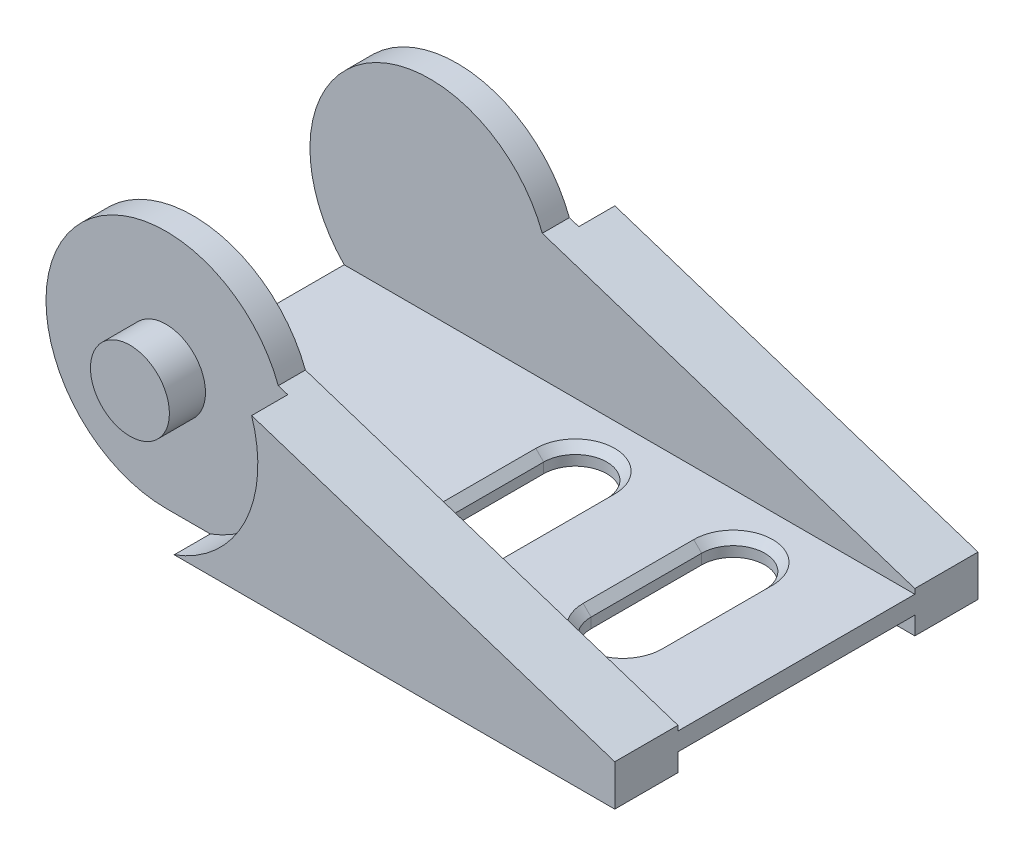
from build123d import *

# Parameters (mm, degrees)
BOSS_EXTRUDE1_DEPTH = 23
CUT_EXTRUDE1_DEPTH  = 24
SKETCH3_W           = 15
SKETCH3_H           = 12.914285714
CUT_EXTRUDE2_DEPTH  = 39.3
CUT_EXTRUDE4_DEPTH  = 3.285714286
SKETCH4_W           = 15
SKETCH4_H           = 1.142857143
CUT_EXTRUDE3_DEPTH  = 39.3
SKETCH_1_R          = 8.1
CUT_EXTRUDE_1_DEPTH = 2.285714
BOSS_EXTRUDE3_START = -2.285714
SKETCH7_R           = 2.5
BOSS_EXTRUDE3_DEPTH = 2.285714
EXTRUDE_START       = -20.714286
SKETCH7_2_R         = 2.5
EXTRUDE_1_DEPTH     = 2.285714
CHAMFER1_SIZE       = 0.5


with BuildPart() as part:
    # Sketch1 → Boss-Extrude1 (new body)
    with BuildSketch(Plane.XY):
        with BuildLine():
            Line((-15.35, 7.6), (15.35, 7.6))
            ThreePointArc((15.35, 7.6), (22.95, 0), (15.35, -7.6))
            Line((15.35, -7.6), (-15.35, -7.6))
            ThreePointArc((-15.35, -7.6), (-22.95, 0), (-15.35, 7.6))
        make_face()
    extrude(amount=-BOSS_EXTRUDE1_DEPTH)

    # Sketch2 → Cut-Extrude1 (cut, through all)
    with BuildSketch(Plane.XY):
        with BuildLine():
            Line((-8.239692572, 2.683938949), (15.35, -5))
            Line((15.35, -5), (15.35, -7.6))
            ThreePointArc((15.35, -7.6), (22.95, 0), (15.35, 7.6))
            Line((15.35, 7.6), (-15.35, 7.6))
            ThreePointArc((-15.35, 7.6), (-11.027844057, 6.251317302), (-8.239692572, 2.683938949))
        make_face()
    extrude(amount=-CUT_EXTRUDE1_DEPTH, mode=Mode.SUBTRACT)

    # Sketch3 → Cut-Extrude2 (cut, through all)
    with BuildSketch(Plane(origin=(15.35, 0, 0), x_dir=(0, 0, -1), z_dir=(1, 0, 0))):
        with Locations((11.5, 1.142857143)):
            Rectangle(SKETCH3_W, SKETCH3_H)
    extrude(amount=-CUT_EXTRUDE2_DEPTH, mode=Mode.SUBTRACT)

    # Sketch5 → Cut-Extrude4 (cut, through all)
    with BuildSketch(Plane(origin=(0, -5.314285714, 0), x_dir=(1, 0, 0), z_dir=(0, 1, 0))):
        with BuildLine():
            Line((9.85, 15), (9.85, 8))
            ThreePointArc((9.85, 8), (7.85, 6), (5.85, 8))
            Line((5.85, 8), (5.85, 15))
            ThreePointArc((5.85, 15), (7.85, 17), (9.85, 15))
        make_face()
        with BuildLine():
            Line((-0.15, 15), (-0.15, 8))
            ThreePointArc((-0.15, 8), (-2.15, 6), (-4.15, 8))
            Line((-4.15, 8), (-4.15, 15))
            ThreePointArc((-4.15, 15), (-2.15, 17), (-0.15, 15))
        make_face()
    extrude(amount=-CUT_EXTRUDE4_DEPTH, mode=Mode.SUBTRACT)

    # Sketch4 → Cut-Extrude3 (cut, through all)
    with BuildSketch(Plane(origin=(15.35, 0, 0), x_dir=(0, 0, -1), z_dir=(1, 0, 0))):
        with Locations((11.5, -7.028571429)):
            Rectangle(SKETCH4_W, SKETCH4_H)
    extrude(amount=-CUT_EXTRUDE3_DEPTH, mode=Mode.SUBTRACT)

    # Sketch 1 → Cut-Extrude 1 (cut)
    with BuildSketch(Plane.XY):
        with Locations((-15.35, 0)):
            Circle(SKETCH_1_R)
    cut_extrude_1 = extrude(amount=-CUT_EXTRUDE_1_DEPTH, mode=Mode.SUBTRACT)

    # Sketch7 → Boss-Extrude3 (add)
    with BuildSketch(Plane.XY.offset(BOSS_EXTRUDE3_START)):
        with Locations((-15.35, 0)):
            Circle(SKETCH7_R)
    extrude(amount=BOSS_EXTRUDE3_DEPTH)

    # Mirror 1: Cut-Extrude 1 across plane
    add(cut_extrude_1.mirror(Plane.XY.offset(-11.5)), mode=Mode.SUBTRACT)

    # Sketch7_2 → Extrude 1 (add)
    with BuildSketch(Plane.XY.offset(EXTRUDE_START)):
        with Locations((-15.35, 0)):
            Circle(SKETCH7_2_R)
    extrude(amount=-EXTRUDE_1_DEPTH)

    # Chamfer1
    chamfer1_edges = [part.edges().sort_by_distance(p)[0] for p in [
        (7.85, -5.314285714, -17),
        (5.85, -5.314285714, -11.5),
        (7.85, -5.314285714, -6),
        (9.85, -5.314285714, -11.5),
        (-2.15, -5.314285714, -17),
        (-4.15, -5.314285714, -11.5),
        (-2.15, -5.314285714, -6),
        (-0.15, -5.314285714, -11.5),
    ]]
    chamfer(chamfer1_edges, length=CHAMFER1_SIZE)


solid = part.part
